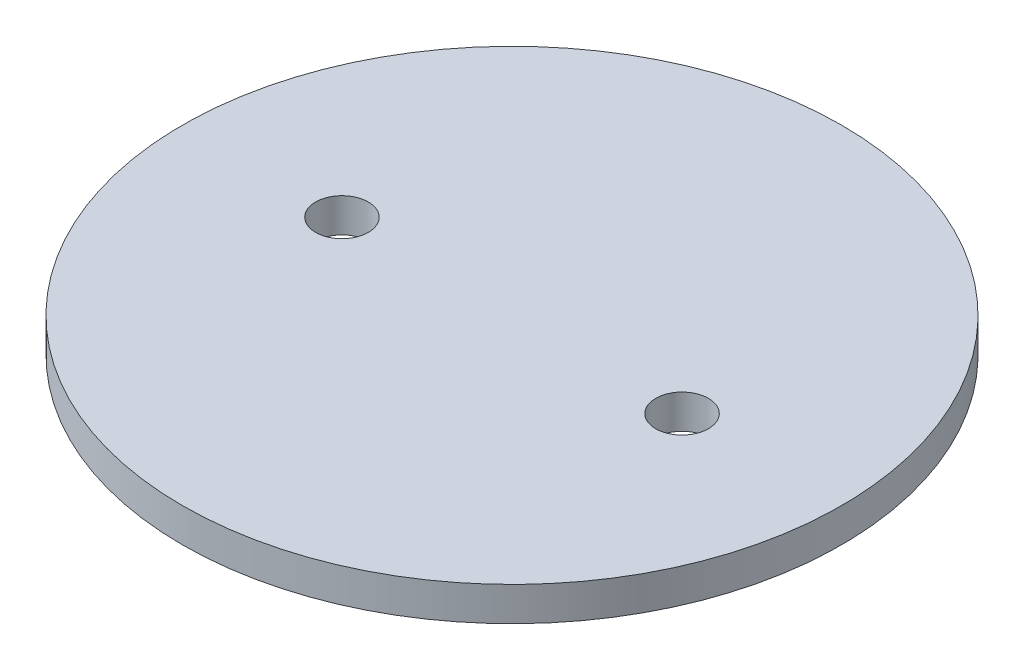
from build123d import *

# Parameters (mm, degrees)
SKETCH1_R           = 96.9
SKETCH1_R_2         = 7.75
BOSS_EXTRUDE1_DEPTH = 10


with BuildPart() as part:
    # Sketch1 → Boss-Extrude1 (new body)
    with BuildSketch(Plane(origin=(0, 0, 0), x_dir=(1, 0, 0), z_dir=(0, 1, 0))):
        Circle(SKETCH1_R)
        with Locations((50, 0)):
            Circle(SKETCH1_R_2, mode=Mode.SUBTRACT)
        with Locations((-50, 0)):
            Circle(SKETCH1_R_2, mode=Mode.SUBTRACT)
    extrude(amount=BOSS_EXTRUDE1_DEPTH)


solid = part.part
